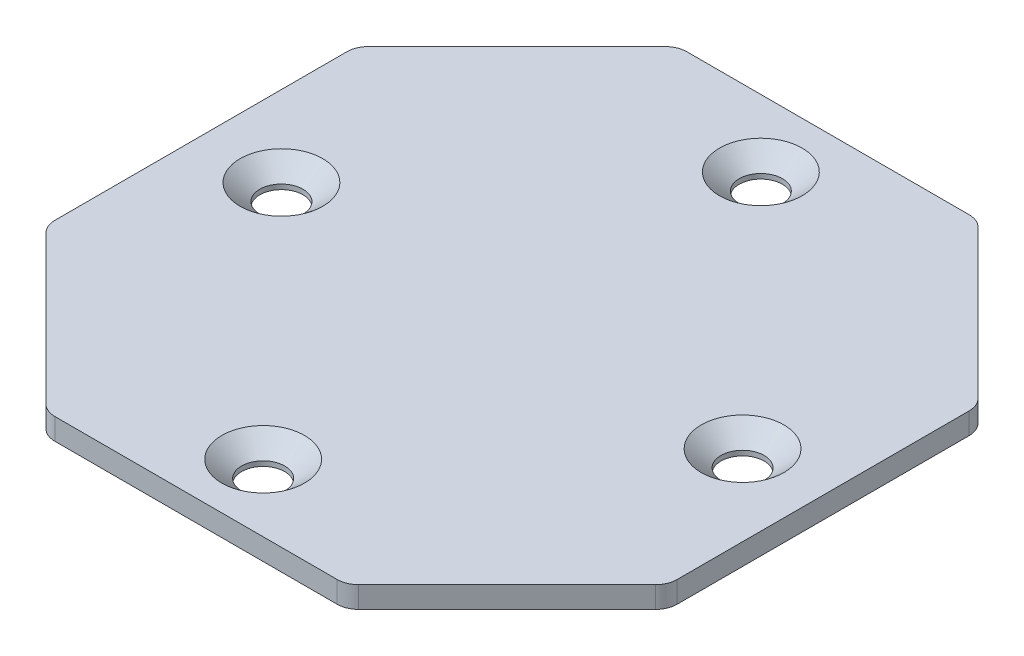
from build123d import *

# Parameters (mm, degrees)
MAIN_BASE_DIM_W                            = 73.60000012
MAIN_BASE_DIM_H                            = 74.750000106
MAIN_BASE_DEPTH                            = 2.54
CSK_FOR_10_FLAT_HEAD_MACHINE_SCREW_2_COUNT = 2
CSK_FOR_10_FLAT_HEAD_MACHINE_SCREW_2_PITCH = 40.130936127
CSK_FOR_10_FLAT_HEAD_MACHINE_SCREW_3_COUNT = 2
CSK_FOR_10_FLAT_HEAD_MACHINE_SCREW_3_PITCH = 54.55000006
CSK_FOR_10_FLAT_HEAD_MACHINE_SCREW_4_COUNT = 2
CSK_FOR_10_FLAT_HEAD_MACHINE_SCREW_4_PITCH = 40.130936127
CONER_CUT_DEPTH                            = 2.54
F_1IN_FILLET_R                             = 2.54


with BuildPart() as part:
    # Main_Base_Dim → Main_Base (new body)
    with BuildSketch(Plane(origin=(0, 0, 0), x_dir=(1, 0, 0), z_dir=(0, 1, 0))):
        with Locations((36.80000006, 37.375000053)):
            Rectangle(MAIN_BASE_DIM_W, MAIN_BASE_DIM_H)
    extrude(amount=MAIN_BASE_DEPTH)

    # Sketch4 → CSK for #10 Flat Head Machine Screw (100)1 (revolve, cut)
    with BuildSketch(Plane(origin=(9.52500003, 2.54, -37.375000053), x_dir=(0, 0, 1), z_dir=(1, 0, 0))):
        Polygon((0, 0), (0, 2.54), (2.5527, 2.54), (2.5527, 1.960808018), (4.8895, 0), align=None)
    csk_for_10_flat_head_machine_screw_100 = revolve(axis=Axis((9.52500003, 8.89, -37.375000053), (0, -1, 0)), mode=Mode.SUBTRACT)

    # CSK for _10 Flat Head Machine Screw  2: CSK for #10 Flat Head Machine Screw (100)1 ×2
    with Locations(*[Vector(0.679650232, 0, 0.73353634) * (i * CSK_FOR_10_FLAT_HEAD_MACHINE_SCREW_2_PITCH) for i in range(1, CSK_FOR_10_FLAT_HEAD_MACHINE_SCREW_2_COUNT)]):
        add(csk_for_10_flat_head_machine_screw_100, mode=Mode.SUBTRACT)

    # CSK for _10 Flat Head Machine Screw  3: CSK for #10 Flat Head Machine Screw (100)1 ×2
    with Locations(*[(i * CSK_FOR_10_FLAT_HEAD_MACHINE_SCREW_3_PITCH, 0, 0) for i in range(1, CSK_FOR_10_FLAT_HEAD_MACHINE_SCREW_3_COUNT)]):
        add(csk_for_10_flat_head_machine_screw_100, mode=Mode.SUBTRACT)

    # CSK for _10 Flat Head Machine Screw  4: CSK for #10 Flat Head Machine Screw (100)1 ×2
    with Locations(*[Vector(0.679650232, 0, -0.73353634) * (i * CSK_FOR_10_FLAT_HEAD_MACHINE_SCREW_4_PITCH) for i in range(1, CSK_FOR_10_FLAT_HEAD_MACHINE_SCREW_4_COUNT)]):
        add(csk_for_10_flat_head_machine_screw_100, mode=Mode.SUBTRACT)

    # Corner_Cut_Dim → Coner_Cut (cut)
    with BuildSketch(Plane(origin=(0, 2.54, 0), x_dir=(1, 0, 0), z_dir=(0, 1, 0))):
        Polygon((0, 0), (0, 19.05), (19.05, 0), align=None)
        Polygon((54.55000012, 0), (73.60000012, 0), (73.60000012, 19.05), align=None)
        Polygon((73.60000012, 74.750000106), (73.60000012, 55.700000106), (54.55000012, 74.750000106), align=None)
        Polygon((0, 55.700000106), (19.05, 74.750000106), (0, 74.750000106), align=None)
    extrude(amount=-CONER_CUT_DEPTH, mode=Mode.SUBTRACT)

    # .1in_Fillet
    f_1in_fillet_edges = [part.edges().sort_by_distance(p)[0] for p in [
        (19.05, 1.27, -74.750000106),
        (0, 1.27, -55.700000106),
        (73.60000012, 1.27, -55.700000106),
        (54.55000012, 1.27, -74.750000106),
        (73.60000012, 1.27, -19.05),
        (54.55000012, 1.27, 0),
        (0, 1.27, -19.05),
        (19.05, 1.27, 0),
    ]]
    fillet(f_1in_fillet_edges, radius=F_1IN_FILLET_R)


solid = part.part
